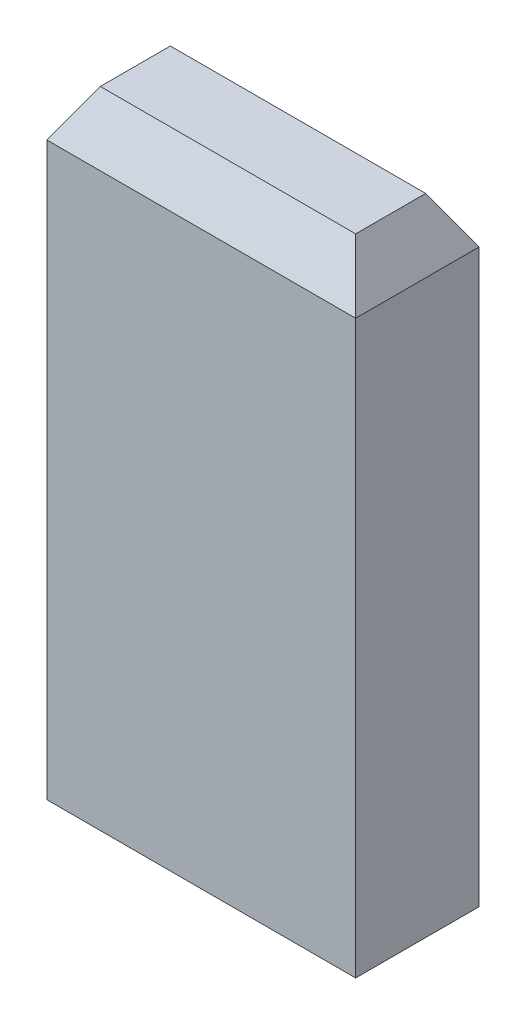
from build123d import *

# Parameters (mm, degrees)
SKETCH1_W             = 2
SKETCH1_H             = 0.8
BOSS_EXTRUDE1_DEPTH   = 4
CHAMFER1_SIZE         = 0.3
CHAMFER1_SIZE2        = 0.173205081
CHAMFER1_PART_2_SIZE  = 0.3
CHAMFER1_PART_2_SIZE2 = 0.173205081
CHAMFER1_PART_3_SIZE  = 0.3
CHAMFER1_PART_3_SIZE2 = 0.173205081
CHAMFER1_PART_4_SIZE  = 0.3
CHAMFER1_PART_4_SIZE2 = 0.173205081


with BuildPart() as part:
    # Sketch1 → Boss-Extrude1 (new body)
    with BuildSketch(Plane(origin=(0, 0, 0), x_dir=(-1, 0, 0), z_dir=(0, 1, 0))):
        with Locations((1, -0.4)):
            Rectangle(SKETCH1_W, SKETCH1_H)
    extrude(amount=BOSS_EXTRUDE1_DEPTH)

    # Chamfer1
    chamfer1_edges = [part.edges().sort_by_distance(p)[0] for p in [
        (-2, 4, -0.4),
    ]]
    chamfer1_side = [part.faces().sort_by_distance(p)[0] for p in [
        (-2, 2, -0.4),
    ]]
    chamfer(chamfer1_edges, length=CHAMFER1_SIZE, length2=CHAMFER1_SIZE2, reference=chamfer1_side[0])

    # Chamfer1 part 2
    chamfer1_part_2_edges = [part.edges().sort_by_distance(p)[0] for p in [
        (-1, 4, 0),
    ]]
    chamfer1_part_2_side = [part.faces().sort_by_distance(p)[0] for p in [
        (-1, 2, 0),
    ]]
    chamfer(chamfer1_part_2_edges, length=CHAMFER1_PART_2_SIZE, length2=CHAMFER1_PART_2_SIZE2, reference=chamfer1_part_2_side[0])

    # Chamfer1 part 3
    chamfer1_part_3_edges = [part.edges().sort_by_distance(p)[0] for p in [
        (0, 4, -0.4),
    ]]
    chamfer1_part_3_side = [part.faces().sort_by_distance(p)[0] for p in [
        (0, 2, -0.4),
    ]]
    chamfer(chamfer1_part_3_edges, length=CHAMFER1_PART_3_SIZE, length2=CHAMFER1_PART_3_SIZE2, reference=chamfer1_part_3_side[0])

    # Chamfer1 part 4
    chamfer1_part_4_edges = [part.edges().sort_by_distance(p)[0] for p in [
        (-1, 4, -0.8),
    ]]
    chamfer1_part_4_side = [part.faces().sort_by_distance(p)[0] for p in [
        (-1, 2, -0.8),
    ]]
    chamfer(chamfer1_part_4_edges, length=CHAMFER1_PART_4_SIZE, length2=CHAMFER1_PART_4_SIZE2, reference=chamfer1_part_4_side[0])


solid = part.part
